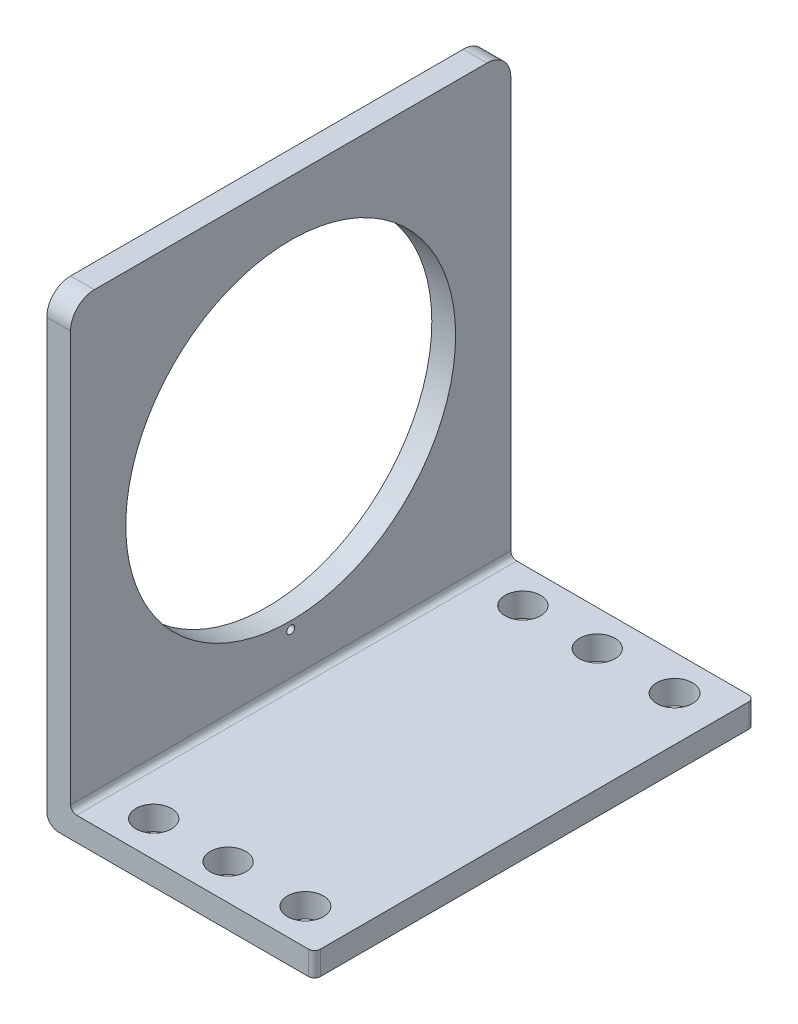
from build123d import *

# Parameters (mm, degrees)
BOSS_EXTRUDE1_DEPTH = 37
SKETCH2_R           = 13.860055969
SKETCH2_R_2         = 0.332739378
CUT_EXTRUDE1_DEPTH  = 10
SKETCH3_R           = 1.513801081
SKETCH3_R_2         = 1.495226131
CUT_EXTRUDE2_DEPTH  = 10
FILLET1_R           = 2
FILLET2_R           = 0.5
FILLET3_R           = 0.5


with BuildPart() as part:
    # Sketch1 → Boss-Extrude1 (new body)
    with BuildSketch(Plane.XY):
        with BuildLine():
            Line((0, 0), (0, 37))
            Line((0, 37), (-2, 37))
            Line((-2, 37), (-2, -1))
            ThreePointArc((-2, -1), (-1.707106781, -1.707106781), (-1, -2))
            Line((-1, -2), (20.5, -2))
            Line((20.5, -2), (20.5, 0))
            Line((20.5, 0), (0, 0))
        make_face()
    extrude(amount=BOSS_EXTRUDE1_DEPTH)

    # Sketch2 → Cut-Extrude1 (cut)
    with BuildSketch(Plane(origin=(0, 0, 0), x_dir=(0, 0, -1), z_dir=(1, 0, 0))):
        with Locations((-18.5, 18.5)):
            Circle(SKETCH2_R)
        with Locations((-18.5, 4)):
            Circle(SKETCH2_R_2)
    extrude(amount=-CUT_EXTRUDE1_DEPTH, mode=Mode.SUBTRACT)

    # Sketch3 → Cut-Extrude2 (cut)
    with BuildSketch(Plane(origin=(0, 0, 0), x_dir=(1, 0, 0), z_dir=(0, 1, 0))):
        with Locations((16.75, -2.987028894)):
            Circle(SKETCH3_R)
        with Locations((10.25, -2.987028894)):
            Circle(SKETCH3_R_2)
        with Locations((4, -2.987028894)):
            Circle(SKETCH3_R_2)
        with Locations((16.75, -34.012971106)):
            Circle(SKETCH3_R)
        with Locations((10.25, -34.012971106)):
            Circle(SKETCH3_R_2)
        with Locations((4, -34.012971106)):
            Circle(SKETCH3_R_2)
    extrude(amount=-CUT_EXTRUDE2_DEPTH, mode=Mode.SUBTRACT)

    # Fillet1
    fillet1_edges = [part.edges().sort_by_distance(p)[0] for p in [
        (-1, 37, 37),
        (-1, 37, 0),
    ]]
    fillet(fillet1_edges, radius=FILLET1_R)

    # Fillet2
    fillet2_edges = [part.edges().sort_by_distance(p)[0] for p in [
        (0, 0, 18.5),
    ]]
    fillet(fillet2_edges, radius=FILLET2_R)

    # Fillet3
    fillet3_edges = [part.edges().sort_by_distance(p)[0] for p in [
        (20.5, -1, 37),
        (20.5, -1, 0),
    ]]
    fillet(fillet3_edges, radius=FILLET3_R)


solid = part.part
